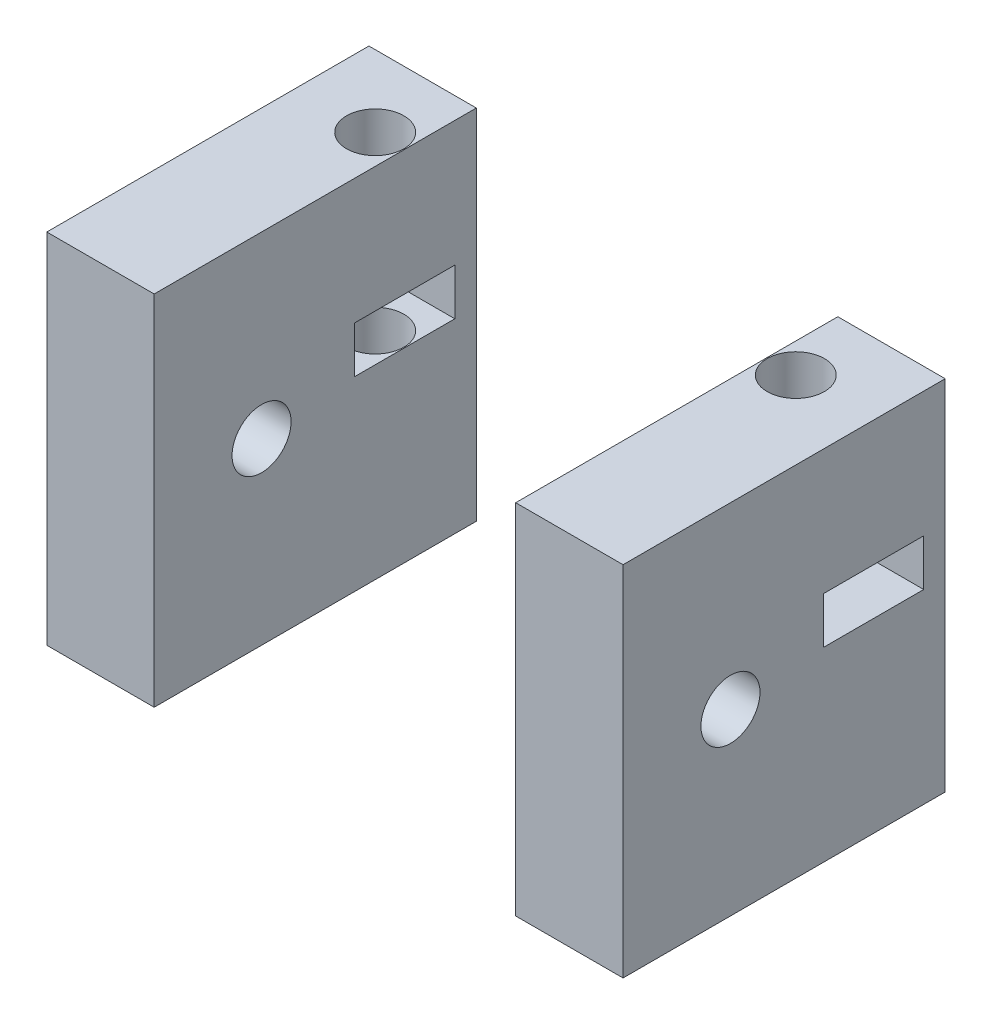
from build123d import *

# Parameters (mm, degrees)
SKETCH_1_W          = 6
SKETCH_1_H          = 18
SKETCH_1_R          = 1.6
EXTRUDE_1_DEPTH     = 20
EXTRUDE_1_2_DEPTH   = 20
SKETCH_2_R          = 1.65
SKETCH_2_W          = 5.6
SKETCH_2_H          = 2.6
CUT_EXTRUDE_1_DEPTH = 33.2


with BuildPart() as part:
    # 草图1 → 凸台-拉伸1 (new body)
    with BuildSketch(Plane(origin=(0, 0, 0), x_dir=(1, 0, 0), z_dir=(0, 1, 0))):
        with Locations((-13.1, -5)):
            Rectangle(SKETCH_1_W, SKETCH_1_H)
        with Locations((-11.75, 0)):
            Circle(SKETCH_1_R, mode=Mode.SUBTRACT)
    extrude(amount=-EXTRUDE_1_DEPTH)


with BuildPart() as body_2:
    # 草图1 → Extrude 1 2 (new body)
    with BuildSketch(Plane(origin=(0, 0, 0), x_dir=(1, 0, 0), z_dir=(0, 1, 0))):
        with Locations((13.1, -5)):
            Rectangle(SKETCH_1_W, SKETCH_1_H)
        with Locations((11.75, 0)):
            Circle(SKETCH_1_R, mode=Mode.SUBTRACT)
    extrude(amount=-EXTRUDE_1_2_DEPTH)


with BuildPart() as cut_extrude_1_tool:
    # 草图2 → 切除-拉伸1 (new body, through all)
    with BuildSketch(Plane(origin=(16.1, 0, 0), x_dir=(0, 0, -1), z_dir=(1, 0, 0))):
        with Locations((-8, -10)):
            Circle(SKETCH_2_R)
        with Locations((0, -8.3)):
            Rectangle(SKETCH_2_W, SKETCH_2_H)
    extrude(amount=-CUT_EXTRUDE_1_DEPTH)


with BuildPart() as part_1:
    add(part.part)

    # 切除-拉伸1: cut by cut_extrude_1_tool
    add(cut_extrude_1_tool.part, mode=Mode.SUBTRACT)


with BuildPart() as body_2_1:
    add(body_2.part)

    # 切除-拉伸1: cut by cut_extrude_1_tool
    add(cut_extrude_1_tool.part, mode=Mode.SUBTRACT)


solid = Compound([part_1.part, body_2_1.part])
